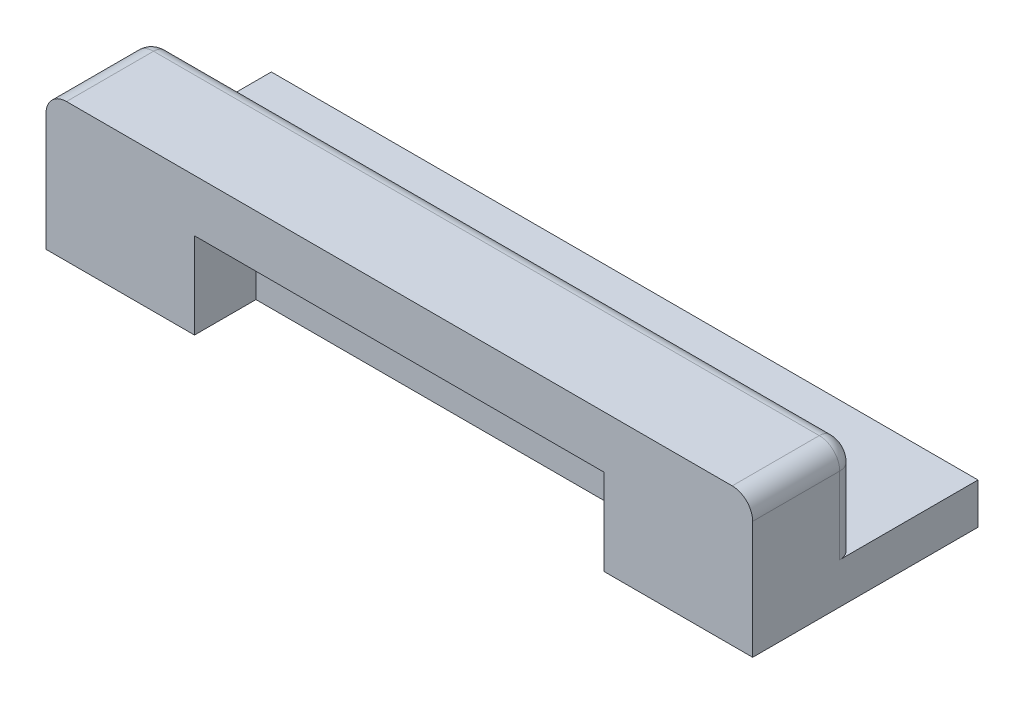
from build123d import *

# Parameters (mm, degrees)
SKETCH1_W                = 69
SKETCH1_H                = 22
BOSS_EXTRUDE1_DEPTH      = 3
BOSS_EXTRUDE1_DEPTH_BACK = 1
BOSS_EXTRUDE2_DEPTH      = 9.5
CUT_EXTRUDE2_DEPTH       = 63
SKETCH5_W                = 40
SKETCH5_H                = 8.4
CUT_EXTRUDE3_DEPTH       = 6
FILLET5_R                = 2
FILLET6_R                = 1.5


with BuildPart() as part:
    # Sketch1 → Boss-Extrude1 (new body, two sides)
    with BuildSketch(Plane(origin=(0, 0, 0), x_dir=(1, 0, 0), z_dir=(0, 1, 0))) as boss_extrude1_sk:
        Rectangle(SKETCH1_W, SKETCH1_H)
    extrude(amount=BOSS_EXTRUDE1_DEPTH)
    extrude(boss_extrude1_sk.sketch, amount=-BOSS_EXTRUDE1_DEPTH_BACK)

    # Sketch2 → Boss-Extrude2 (add)
    with BuildSketch(Plane(origin=(0, 3, 0), x_dir=(1, 0, 0), z_dir=(0, 1, 0))):
        Polygon((-34.5, -11), (-21.5, -11), (21.5, -11), (34.5, -11), (34.5, -1), (21.5, -1), (-21.5, -1), (-34.5, -1), align=None)
    extrude(amount=BOSS_EXTRUDE2_DEPTH)

    # Sketch4 → Cut-Extrude2 (cut)
    with BuildSketch(Plane(origin=(31.5, 0, 0), x_dir=(0, 0, -1), z_dir=(1, 0, 0))):
        Polygon((-1, 3), (-3.5, 7.5), (-1, 7.5), align=None)
    extrude(amount=-CUT_EXTRUDE2_DEPTH, mode=Mode.SUBTRACT)

    # Sketch5 → Cut-Extrude3 (cut)
    with BuildSketch(Plane.XY.offset(11)):
        with Locations((0, 3.2)):
            Rectangle(SKETCH5_W, SKETCH5_H)
    extrude(amount=-CUT_EXTRUDE3_DEPTH, mode=Mode.SUBTRACT)

    # Fillet5
    fillet5_edges = [part.edges().sort_by_distance(p)[0] for p in [
        (-34.5, 12.5, 6),
        (34.5, 12.5, 6),
    ]]
    fillet(fillet5_edges, radius=FILLET5_R)

    # Fillet6
    fillet6_edges = [part.edges().sort_by_distance(p)[0] for p in [
        (0, 12.5, 1),
        (-34.5, 6.75, 1),
        (34.5, 6.75, 1),
        (33.914213562, 11.914213562, 1),
        (-33.914213562, 11.914213562, 1),
    ]]
    fillet(fillet6_edges, radius=FILLET6_R)


solid = part.part
